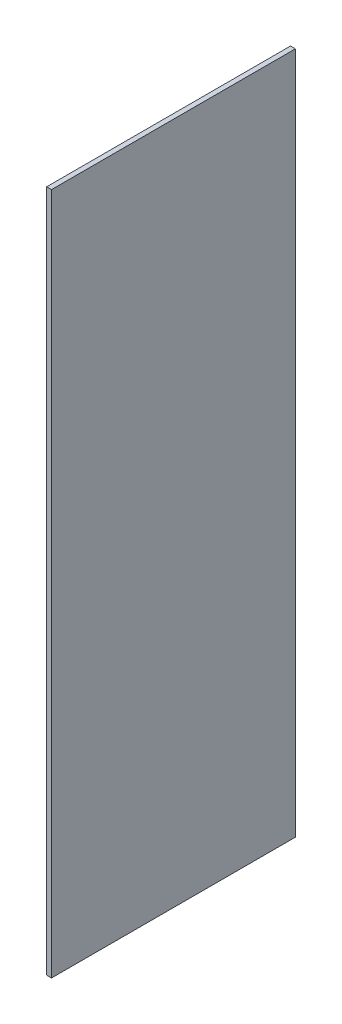
from build123d import *

# Parameters (mm, degrees)
SKETCH1_W           = 0.1
SKETCH1_H           = 14
BOSS_EXTRUDE1_DEPTH = 5


with BuildPart() as part:
    # Sketch1 → Boss-Extrude1 (new body)
    with BuildSketch(Plane.XY):
        with Locations((0.05, 7)):
            Rectangle(SKETCH1_W, SKETCH1_H)
    extrude(amount=BOSS_EXTRUDE1_DEPTH)


solid = part.part
